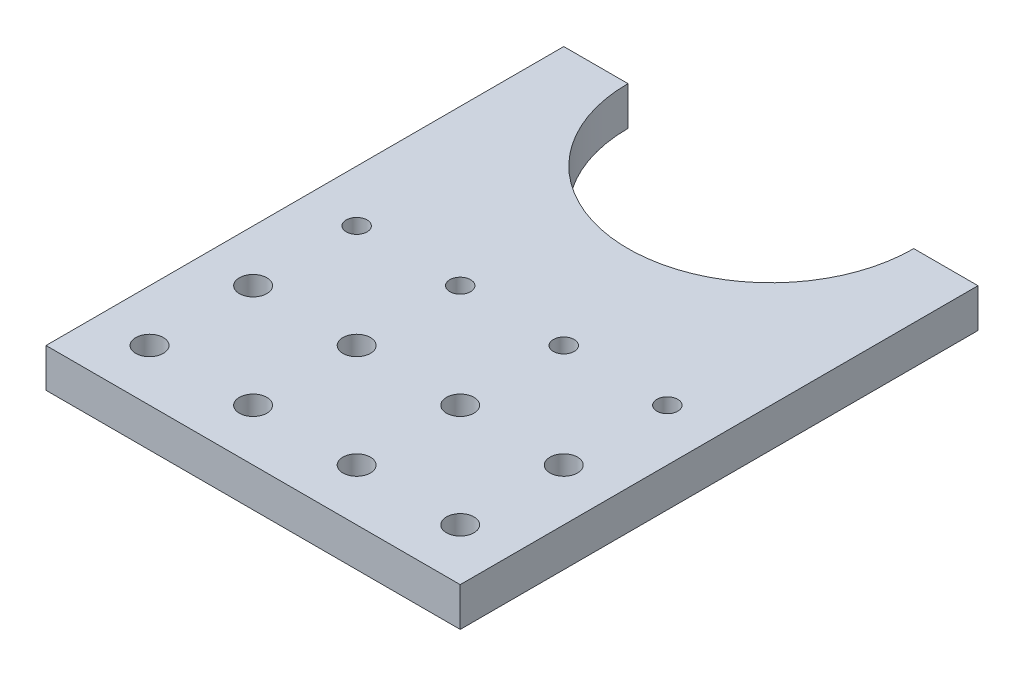
from build123d import *

# Parameters (mm, degrees)
SKETCH1_W                   = 101.6
SKETCH1_H                   = 127
BOSS_EXTRUDE1_DEPTH         = 9.525
SKETCH2_R                   = 35.052
CUT_EXTRUDE1_DEPTH          = 10.525
F_1_4_CLEARANCE_HOLE1_D     = 6.7564
LPATTERN1_COUNT             = 2
LPATTERN1_PITCH             = 25.4
LPATTERN1_COUNT_DIR2        = 4
LPATTERN1_PITCH_DIR2        = 25.4
TAP_DRILL_FOR_1_4_20_TAP1_D = 5.1054
LPATTERN2_COUNT             = 4
LPATTERN2_PITCH             = 25.4


with BuildPart() as part:
    # Sketch1 → Boss-Extrude1 (new body)
    with BuildSketch(Plane(origin=(0, 0, 0), x_dir=(1, 0, 0), z_dir=(0, 1, 0))):
        with Locations((50.8, 63.5)):
            Rectangle(SKETCH1_W, SKETCH1_H)
    extrude(amount=BOSS_EXTRUDE1_DEPTH)

    # Sketch2 → Cut-Extrude1 (cut, through all)
    with BuildSketch(Plane(origin=(0, 9.525, 0), x_dir=(1, 0, 0), z_dir=(0, 1, 0))):
        with Locations((50.8, 127)):
            Circle(SKETCH2_R)
    extrude(amount=-CUT_EXTRUDE1_DEPTH, mode=Mode.SUBTRACT)

    # 1/4 Clearance Hole1 (through all)
    with Locations(Plane(origin=(0, 9.525, 0), x_dir=(-1, 0, 0), z_dir=(0, 1, 0))):
        with Locations((-12.7, -12.7)):
            f_1_4_clearance_hole1 = Hole(F_1_4_CLEARANCE_HOLE1_D / 2)

    # LPattern1: 1_4 Clearance Hole1 2 × 4
    with Locations(*[(j * LPATTERN1_PITCH_DIR2, 0, -i * LPATTERN1_PITCH) for i in range(LPATTERN1_COUNT) for j in range(LPATTERN1_COUNT_DIR2) if (i, j) != (0, 0)]):
        add(f_1_4_clearance_hole1, mode=Mode.SUBTRACT)

    # Tap Drill for 1/4-20 Tap1 (through all)
    with Locations(Plane(origin=(0, 9.525, 0), x_dir=(-1, 0, 0), z_dir=(0, 1, 0))):
        with Locations((-12.7, -63.5)):
            tap_drill_for_1_4_20_tap1 = Hole(TAP_DRILL_FOR_1_4_20_TAP1_D / 2)

    # LPattern2: Tap Drill for 1/4-20 Tap1 ×4
    with Locations(*[(i * LPATTERN2_PITCH, 0, 0) for i in range(1, LPATTERN2_COUNT)]):
        add(tap_drill_for_1_4_20_tap1, mode=Mode.SUBTRACT)


solid = part.part
